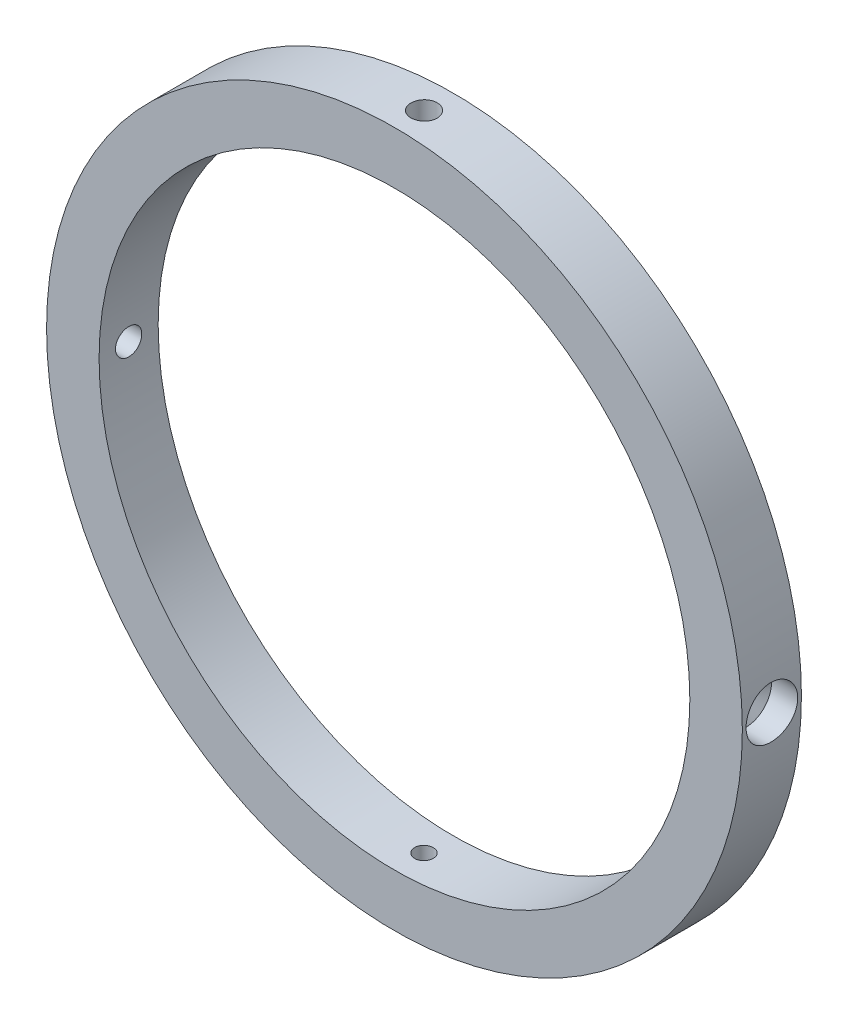
from build123d import *

# Parameters (mm, degrees)
SKETCH1_R           = 42.06875
SKETCH1_R_2         = 35.71875
BOSS_EXTRUDE1_DEPTH = 3.571875
HOLE1_D             = 3.175
HOLE1_DEPTH         = 2.38125
CIRPATTERN1_COUNT   = 2


with BuildPart() as part:
    # Sketch1 → Boss-Extrude1 (new body, symmetric)
    with BuildSketch(Plane.XY):
        Circle(SKETCH1_R)
        Circle(SKETCH1_R_2, mode=Mode.SUBTRACT)
    extrude(amount=BOSS_EXTRUDE1_DEPTH, both=True)

    # Hole1
    with Locations(Plane(origin=(0, 42.06875, 0), x_dir=(1, 0, 0), z_dir=(0, 1, 0))):
        with Locations((0, 0)):
            hole1 = Hole(HOLE1_D / 2, depth=HOLE1_DEPTH)

    # Sketch7 → #4-40 Tapped Hole1 (revolve, cut)
    with BuildSketch(Plane(origin=(0, 39.6875, 0), x_dir=(0, 0, 1), z_dir=(1, 0, 0))):
        Polygon((0, 0), (0, 8.299152758), (1.1303, 7.62), (1.1303, 0), align=None)
    f_4_40_tapped_hole1 = revolve(axis=Axis((0, 46.0375, 0), (0, -1, 0)), mode=Mode.SUBTRACT)

    # Sketch8 → Hole2 (revolve, cut)
    with BuildSketch(Plane(origin=(-42.06875, 0, 0), x_dir=(0, 0, 1), z_dir=(0, 1, 0))):
        Polygon((0, 0), (0, 12.7), (1.5875, 12.7), (1.5875, 4.098342513), (3.1242, 3.175), (3.1242, 0), align=None)
    hole2 = revolve(axis=Axis((-48.198773899, 0, 0), (1, 0, 0)), mode=Mode.SUBTRACT)

    # CirPattern1: Hole1, #4-40 Tapped Hole1, Hole2 ×2 about axis
    cirpattern1_axis = Axis((0, 0, 3.571875), (0, 0, -1))
    for i in range(1, CIRPATTERN1_COUNT):
        add(hole1.rotate(cirpattern1_axis, i * 360 / CIRPATTERN1_COUNT), mode=Mode.SUBTRACT)
        add(f_4_40_tapped_hole1.rotate(cirpattern1_axis, i * 360 / CIRPATTERN1_COUNT), mode=Mode.SUBTRACT)
        add(hole2.rotate(cirpattern1_axis, i * 360 / CIRPATTERN1_COUNT), mode=Mode.SUBTRACT)


solid = part.part
